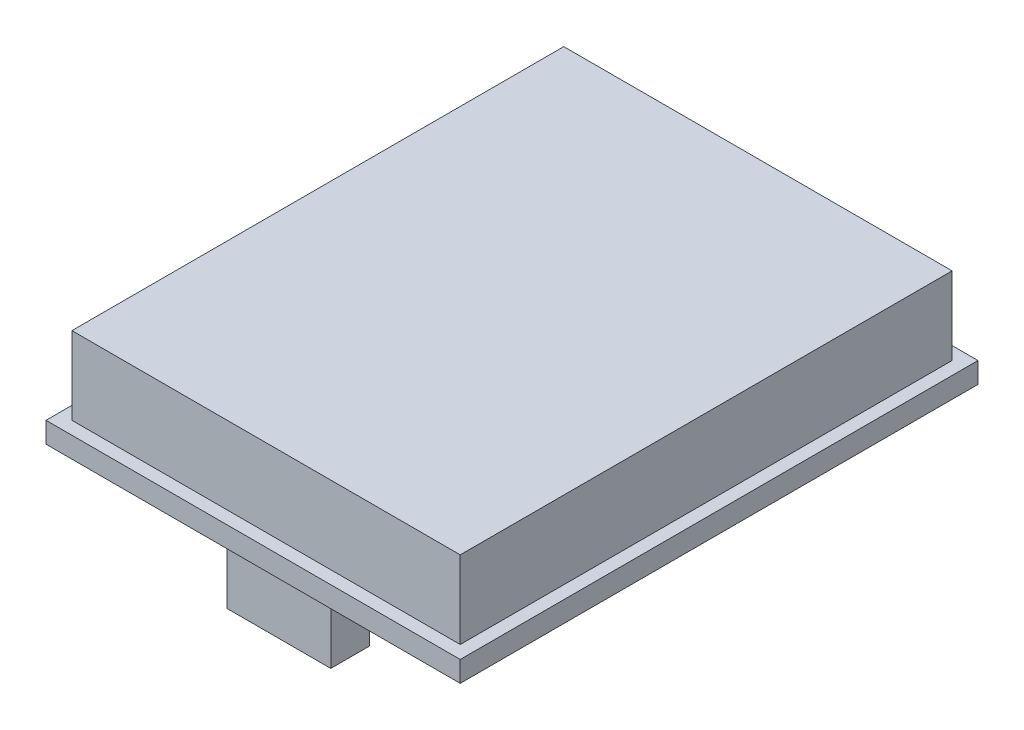
from build123d import *

# Parameters (mm, degrees)
SKETCH1_W           = 32
SKETCH1_H           = 40
BOSS_EXTRUDE1_DEPTH = 1.6
SKETCH2_W           = 30
SKETCH2_H           = 38
BOSS_EXTRUDE2_DEPTH = 6
SKETCH3_W           = 8
SKETCH3_H           = 3
BOSS_EXTRUDE3_DEPTH = 6


with BuildPart() as part:
    # Sketch1 → Boss-Extrude1 (new body)
    with BuildSketch(Plane(origin=(0, 0, 0), x_dir=(1, 0, 0), z_dir=(0, 1, 0))):
        with Locations((16, 20)):
            Rectangle(SKETCH1_W, SKETCH1_H)
    extrude(amount=BOSS_EXTRUDE1_DEPTH)

    # Sketch2 → Boss-Extrude2 (add)
    with BuildSketch(Plane(origin=(0, 1.6, 0), x_dir=(1, 0, 0), z_dir=(0, 1, 0))):
        with Locations((16, 20)):
            Rectangle(SKETCH2_W, SKETCH2_H)
    extrude(amount=BOSS_EXTRUDE2_DEPTH)

    # Sketch3 → Boss-Extrude3 (add)
    with BuildSketch(Plane.XZ):
        with Locations((16, -3.5)):
            Rectangle(SKETCH3_W, SKETCH3_H)
    extrude(amount=BOSS_EXTRUDE3_DEPTH)


solid = part.part
